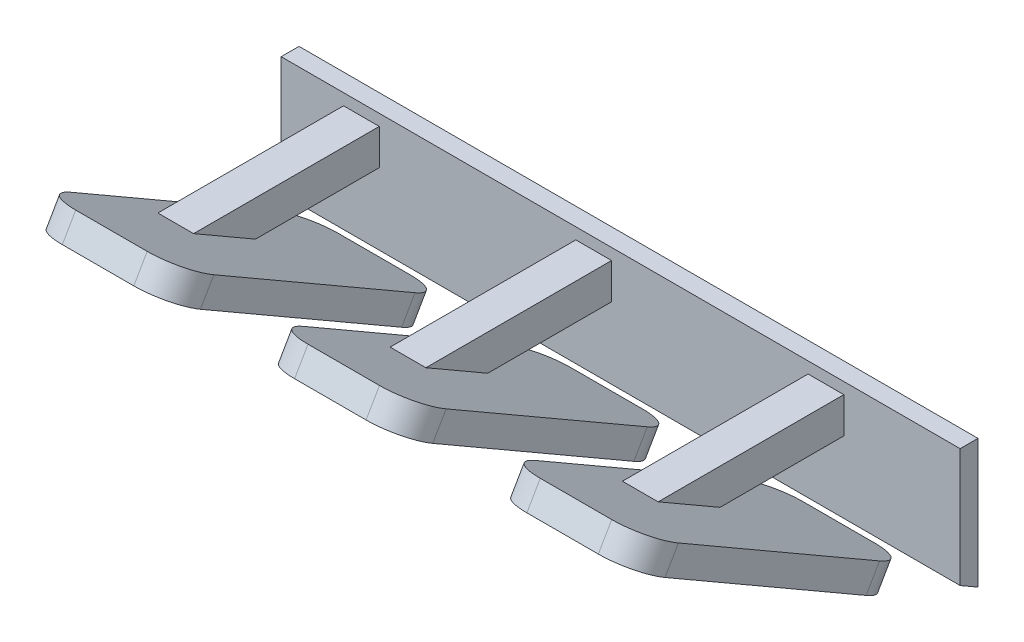
from build123d import *

# Parameters (mm, degrees)
SKETCH1_W           = 50
SKETCH1_H           = 30
BOSS_EXTRUDE1_DEPTH = 1
BOSS_EXTRUDE2_DEPTH = 50
SKETCH3_W           = 50
SKETCH3_H           = 20.262529014
SKETCH3_W_2         = 8
SKETCH3_H_2         = 17
CUT_EXTRUDE1_DEPTH  = 1.5
BOSS_EXTRUDE3_REACH = 18.249
SKETCH4_W           = 2
SKETCH4_H           = 2
CUT_EXTRUDE2_DEPTH  = 50
SKETCH6_W           = 12
SKETCH6_H           = 25.737309448
CUT_EXTRUDE3_DEPTH  = 1
SKETCH7_W           = 38
SKETCH7_H           = 17.625558307
CUT_EXTRUDE4_DEPTH  = 1
FILLET1_R           = 2
FILLET2_R           = 2


with BuildPart() as part:
    # Sketch1 → Boss-Extrude1 (new body)
    with BuildSketch(Plane.XY):
        Rectangle(SKETCH1_W, SKETCH1_H)
    extrude(amount=BOSS_EXTRUDE1_DEPTH)

    # Sketch2 → Boss-Extrude2 (add, through all)
    with BuildSketch(Plane(origin=(25, 0, 0), x_dir=(0, 0, -1), z_dir=(1, 0, 0))):
        Polygon((-1, -10.993105909), (-18.547864871, -0.861841403), (-17.797864871, 0.437196703), (-1, -9.261055102), align=None)
    extrude(amount=-BOSS_EXTRUDE2_DEPTH)

    # Sketch3 → Cut-Extrude1 (cut)
    with BuildSketch(Plane(origin=(0, -8.677842134, 5.010154492), x_dir=(1, 0, 0), z_dir=(0, -0.866025404, 0.5))):
        with Locations((0, 5.500736956)):
            Rectangle(SKETCH3_W, SKETCH3_H)
        with Locations((19, 5.632001463)):
            Rectangle(SKETCH3_W_2, SKETCH3_H_2, mode=Mode.SUBTRACT)
        with Locations((6, 5.632001463)):
            Rectangle(SKETCH3_W_2, SKETCH3_H_2, mode=Mode.SUBTRACT)
        with Locations((-7, 5.632001463)):
            Rectangle(SKETCH3_W_2, SKETCH3_H_2, mode=Mode.SUBTRACT)
    extrude(amount=-CUT_EXTRUDE1_DEPTH, mode=Mode.SUBTRACT)

    # Boss-Extrude3: up to this face of the body (flat: up to its plane)
    boss_extrude3_end = Plane(part.part.faces().sort_by_distance((19, -5.861841403, 9.887610833))[0])
    # Sketch4 → Boss-Extrude3 (add, up to the picked face)
    with BuildSketch(Plane.XY.offset(1), mode=Mode.PRIVATE) as boss_extrude3_sk1:
        with Locations((17.490902079, -4.261055102)):
            Rectangle(SKETCH4_W, SKETCH4_H)
    boss_extrude3_tool1 = split(extrude(boss_extrude3_sk1.sketch, amount=BOSS_EXTRUDE3_REACH, mode=Mode.PRIVATE), bisect_by=boss_extrude3_end, keep=Keep.BOTH, mode=Mode.PRIVATE)
    add(boss_extrude3_tool1.solids().sort_by_distance((17.490902, -4.261055, 1))[0])
    # Sketch4 → Boss-Extrude3 (add, up to the picked face)
    with BuildSketch(Plane.XY.offset(1), mode=Mode.PRIVATE) as boss_extrude3_sk2:
        with Locations((4.490902079, -4.261055102)):
            Rectangle(SKETCH4_W, SKETCH4_H)
    boss_extrude3_tool2 = split(extrude(boss_extrude3_sk2.sketch, amount=BOSS_EXTRUDE3_REACH, mode=Mode.PRIVATE), bisect_by=boss_extrude3_end, keep=Keep.BOTH, mode=Mode.PRIVATE)
    add(boss_extrude3_tool2.solids().sort_by_distance((4.490902, -4.261055, 1))[0])
    # Sketch4 → Boss-Extrude3 (add, up to the picked face)
    with BuildSketch(Plane.XY.offset(1), mode=Mode.PRIVATE) as boss_extrude3_sk3:
        with Locations((-8.509097921, -4.261055102)):
            Rectangle(SKETCH4_W, SKETCH4_H)
    boss_extrude3_tool3 = split(extrude(boss_extrude3_sk3.sketch, amount=BOSS_EXTRUDE3_REACH, mode=Mode.PRIVATE), bisect_by=boss_extrude3_end, keep=Keep.BOTH, mode=Mode.PRIVATE)
    add(boss_extrude3_tool3.solids().sort_by_distance((-8.509098, -4.261055, 1))[0])

    # Sketch5 → Cut-Extrude2 (cut)
    with BuildSketch(Plane.ZY.offset(25)):
        Polygon((0.250581886, -9.69507566), (0, -9.840198507), (0, -15), (1, -15), (1, -10.993105909), align=None)
    extrude(amount=-CUT_EXTRUDE2_DEPTH, mode=Mode.SUBTRACT)

    # Sketch6 → Cut-Extrude3 (cut)
    with BuildSketch(Plane.XY.offset(1)):
        with Locations((-19, 2.131345276)):
            Rectangle(SKETCH6_W, SKETCH6_H)
    extrude(amount=-CUT_EXTRUDE3_DEPTH, mode=Mode.SUBTRACT)

    # Sketch7 → Cut-Extrude4 (cut)
    with BuildSketch(Plane.XY.offset(1)):
        with Locations((6, 6.187220847)):
            Rectangle(SKETCH7_W, SKETCH7_H)
    extrude(amount=-CUT_EXTRUDE4_DEPTH, mode=Mode.SUBTRACT)

    # Fillet1
    fillet1_edges = [part.edges().sort_by_distance(p)[0] for p in [
        (-3, -9.46232235, 2.151394901),
        (-3, -0.96232235, 16.873826765),
        (-11, -0.96232235, 16.873826765),
        (-11, -9.46232235, 2.151394901),
    ]]
    fillet(fillet1_edges, radius=FILLET1_R)

    # Fillet2
    fillet2_edges = [part.edges().sort_by_distance(p)[0] for p in [
        (23, -9.46232235, 2.151394901),
        (23, -0.96232235, 16.873826765),
        (15, -0.96232235, 16.873826765),
        (15, -9.46232235, 2.151394901),
        (10, -9.46232235, 2.151394901),
        (10, -0.96232235, 16.873826765),
        (2, -0.96232235, 16.873826765),
        (2, -9.46232235, 2.151394901),
    ]]
    fillet(fillet2_edges, radius=FILLET2_R)


solid = part.part
